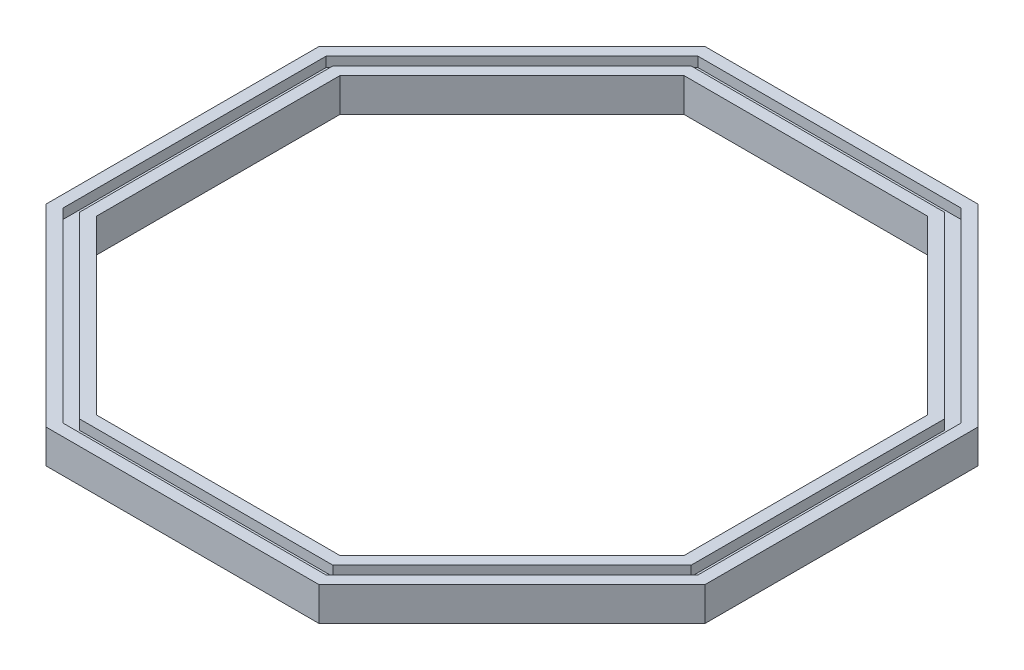
from build123d import *

# Parameters (mm, degrees)
EXTRUDE_1_DEPTH     = 1.7
CUT_EXTRUDE_3_DEPTH = 1
CUT_EXTRUDE_4_DEPTH = 2.7


with BuildPart() as part:
    # 스케치1 → 보스-돌출1 (new body)
    with BuildSketch(Plane(origin=(0, 0, 0), x_dir=(1, 0, 0), z_dir=(0, 1, 0))):
        Polygon((-33.25966317, -13.776603565), (-13.776603565, -33.25966317), (13.776603565, -33.25966317), (33.25966317, -13.776603565), (33.25966317, 13.776603565), (13.776603565, 33.25966317), (-13.776603565, 33.25966317), (-33.25966317, 13.776603565), align=None)
        Polygon((-13.27954729, -32.05966317), (13.27954729, -32.05966317), (32.05966317, -13.27954729), (32.05966317, 13.27954729), (13.27954729, 32.05966317), (-13.27954729, 32.05966317), (-32.05966317, 13.27954729), (-32.05966317, -13.27954729), align=None, mode=Mode.SUBTRACT)
        Polygon((-32.05966317, -13.27954729), (-13.27954729, -32.05966317), (13.27954729, -32.05966317), (32.05966317, -13.27954729), (32.05966317, 13.27954729), (13.27954729, 32.05966317), (-13.27954729, 32.05966317), (-32.05966317, 13.27954729), align=None)
        Polygon((-12.782491015, -30.85966317), (12.782491015, -30.85966317), (30.85966317, -12.782491015), (30.85966317, 12.782491015), (12.782491015, 30.85966317), (-12.782491015, 30.85966317), (-30.85966317, 12.782491015), (-30.85966317, -12.782491015), align=None, mode=Mode.SUBTRACT)
        Polygon((-30.85966317, -12.782491015), (-12.782491015, -30.85966317), (12.782491015, -30.85966317), (30.85966317, -12.782491015), (30.85966317, 12.782491015), (12.782491015, 30.85966317), (-12.782491015, 30.85966317), (-30.85966317, 12.782491015), align=None)
    extrude_1 = extrude(amount=EXTRUDE_1_DEPTH)

    # 스케치2 → 컷-돌출3 (cut)
    with BuildSketch(Plane(origin=(0, 1.7, 0), x_dir=(1, 0, 0), z_dir=(0, 1, 0))):
        Polygon((-32.05966317, -13.27954729), (-13.27954729, -32.05966317), (13.27954729, -32.05966317), (32.05966317, -13.27954729), (32.05966317, 13.27954729), (13.27954729, 32.05966317), (-13.27954729, 32.05966317), (-32.05966317, 13.27954729), align=None)
        Polygon((-30.85966317, -12.782491015), (-12.782491015, -30.85966317), (12.782491015, -30.85966317), (30.85966317, -12.782491015), (30.85966317, 12.782491015), (12.782491015, 30.85966317), (-12.782491015, 30.85966317), (-30.85966317, 12.782491015), align=None, mode=Mode.SUBTRACT)
    cut_extrude_3 = extrude(amount=-CUT_EXTRUDE_3_DEPTH, mode=Mode.SUBTRACT)

    # 스케치3 → 컷-돌출4 (cut, through all)
    with BuildSketch(Plane(origin=(0, 1.7, 0), x_dir=(1, 0, 0), z_dir=(0, 1, 0))):
        Polygon((-12.285434741, 29.65966317), (-29.65966317, 12.285434741), (-29.65966317, -12.285434741), (-12.285434741, -29.65966317), (12.285434741, -29.65966317), (29.65966317, -12.285434741), (29.65966317, 12.285434741), (12.285434741, 29.65966317), align=None)
    cut_extrude_4 = extrude(amount=-CUT_EXTRUDE_4_DEPTH, mode=Mode.SUBTRACT)

    # 대칭 복사1: 보스-돌출1, 컷-돌출3, 컷-돌출4 across plane
    add(extrude_1.mirror(Plane.ZX))
    add(cut_extrude_3.mirror(Plane.ZX), mode=Mode.SUBTRACT)
    add(cut_extrude_4.mirror(Plane.ZX), mode=Mode.SUBTRACT)


solid = part.part
